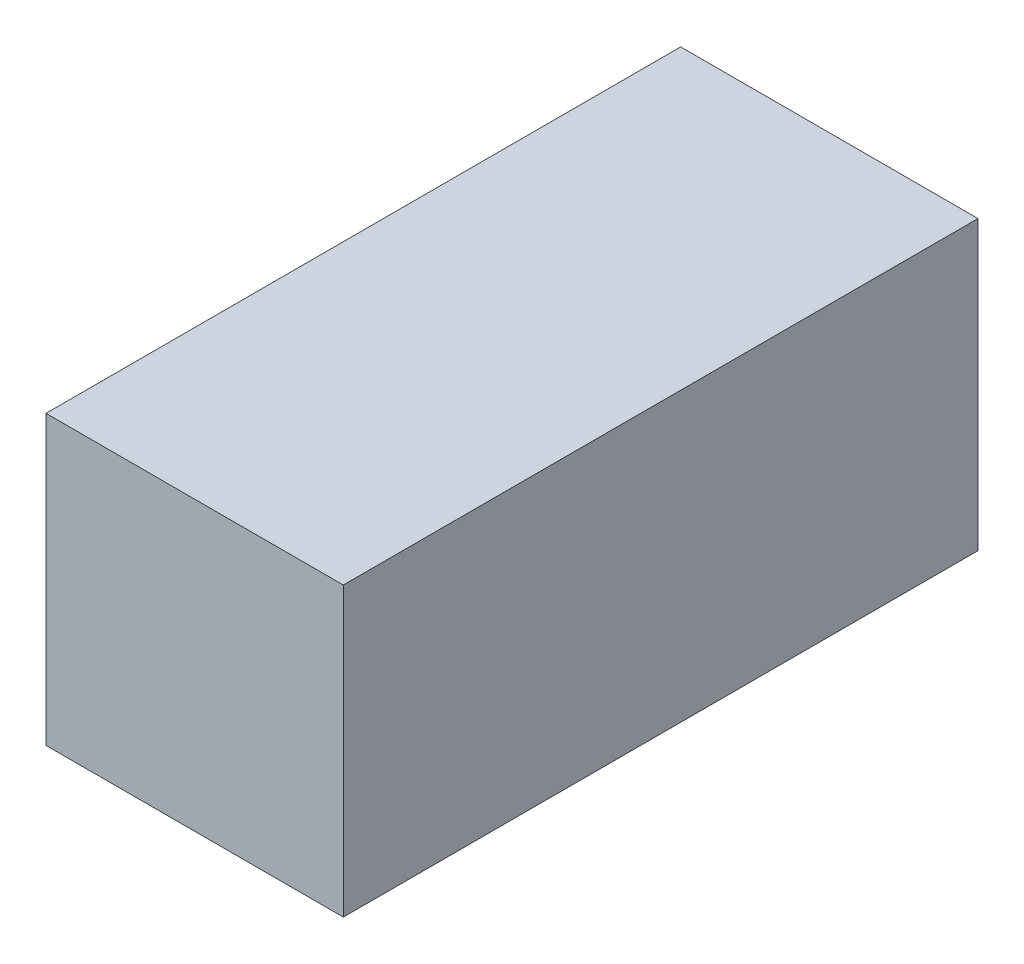
from build123d import *

# Parameters (mm, degrees)
SKETCH2_W      = 24.5
SKETCH2_H      = 23.7
EXTRUDE1_DEPTH = 52.3


with BuildPart() as part:
    # Sketch2 → Extrude1 (new body)
    with BuildSketch(Plane.XY):
        Rectangle(SKETCH2_W, SKETCH2_H)
    extrude(amount=EXTRUDE1_DEPTH)


solid = part.part
